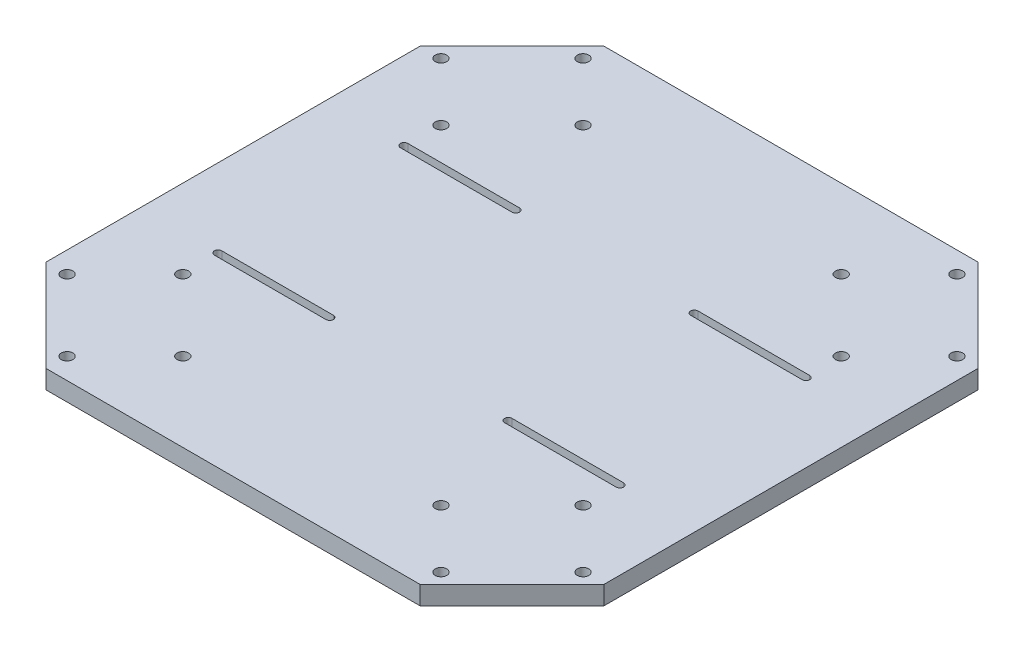
from build123d import *

# Parameters (mm, degrees)
SKETCH1_W           = 150
SKETCH1_H           = 150
BOSS_EXTRUDE1_DEPTH = 2.5
CUT_EXTRUDE1_DEPTH  = 5
SKETCH3_R           = 1.55
CUT_EXTRUDE2_DEPTH  = 5
CUT_EXTRUDE3_DEPTH  = 5


with BuildPart() as part:
    # Sketch1 → Boss-Extrude1 (new body, symmetric)
    with BuildSketch(Plane(origin=(0, 0, 0), x_dir=(1, 0, 0), z_dir=(0, 1, 0))):
        Rectangle(SKETCH1_W, SKETCH1_H)
    extrude(amount=BOSS_EXTRUDE1_DEPTH, both=True)

    # Sketch2 → Cut-Extrude1 (cut)
    with BuildSketch(Plane(origin=(0, 2.5, 0), x_dir=(1, 0, 0), z_dir=(0, 1, 0))):
        Polygon((50.251262658, 75), (75, 75), (75, 50.251262658), align=None)
        Polygon((-75, 75), (-75, 50.251262658), (-50.251262658, 75), align=None)
        Polygon((-50.251262658, -75), (-75, -75), (-75, -50.251262658), align=None)
        Polygon((75, -75), (75, -50.251262658), (50.251262658, -75), align=None)
    extrude(amount=-CUT_EXTRUDE1_DEPTH, mode=Mode.SUBTRACT)

    # Sketch3 → Cut-Extrude2 (cut)
    with BuildSketch(Plane(origin=(0, 2.5, 0), x_dir=(1, 0, 0), z_dir=(0, 1, 0))):
        with Locations((69.343145751, 50.251262658)):
            Circle(SKETCH3_R)
        with Locations((53.786796564, 34.694913472)):
            Circle(SKETCH3_R)
        with Locations((34.694913472, 53.786796564)):
            Circle(SKETCH3_R)
        with Locations((50.251262658, 69.343145751)):
            Circle(SKETCH3_R)
        with Locations((-69.343145751, 50.251262658)):
            Circle(SKETCH3_R)
        with Locations((-53.786796564, 34.694913472)):
            Circle(SKETCH3_R)
        with Locations((-34.694913472, 53.786796564)):
            Circle(SKETCH3_R)
        with Locations((-50.251262658, 69.343145751)):
            Circle(SKETCH3_R)
        with Locations((-53.786796564, -34.694913472)):
            Circle(SKETCH3_R)
        with Locations((-69.343145751, -50.251262658)):
            Circle(SKETCH3_R)
        with Locations((-34.694913472, -53.786796564)):
            Circle(SKETCH3_R)
        with Locations((-50.251262658, -69.343145751)):
            Circle(SKETCH3_R)
        with Locations((69.343145751, -50.251262658)):
            Circle(SKETCH3_R)
        with Locations((53.786796564, -34.694913472)):
            Circle(SKETCH3_R)
        with Locations((34.694913472, -53.786796564)):
            Circle(SKETCH3_R)
        with Locations((50.251262658, -69.343145751)):
            Circle(SKETCH3_R)
    extrude(amount=-CUT_EXTRUDE2_DEPTH, mode=Mode.SUBTRACT)

    # Sketch4 → Cut-Extrude3 (cut)
    with BuildSketch(Plane(origin=(0, 2.5, 0), x_dir=(1, 0, 0), z_dir=(0, 1, 0))):
        with BuildLine():
            Line((24, 26), (54, 26))
            ThreePointArc((54, 26), (55, 25), (54, 24))
            Line((54, 24), (24, 24))
            ThreePointArc((24, 24), (23, 25), (24, 26))
        make_face()
        with BuildLine():
            Line((24, -26), (54, -26))
            ThreePointArc((54, -26), (55, -25), (54, -24))
            Line((54, -24), (24, -24))
            ThreePointArc((24, -24), (23, -25), (24, -26))
        make_face()
        with BuildLine():
            Line((-24, -26), (-54, -26))
            ThreePointArc((-54, -26), (-55, -25), (-54, -24))
            Line((-54, -24), (-24, -24))
            ThreePointArc((-24, -24), (-23, -25), (-24, -26))
        make_face()
        with BuildLine():
            Line((-24, 26), (-54, 26))
            ThreePointArc((-54, 26), (-55, 25), (-54, 24))
            Line((-54, 24), (-24, 24))
            ThreePointArc((-24, 24), (-23, 25), (-24, 26))
        make_face()
    extrude(amount=-CUT_EXTRUDE3_DEPTH, mode=Mode.SUBTRACT)


solid = part.part
